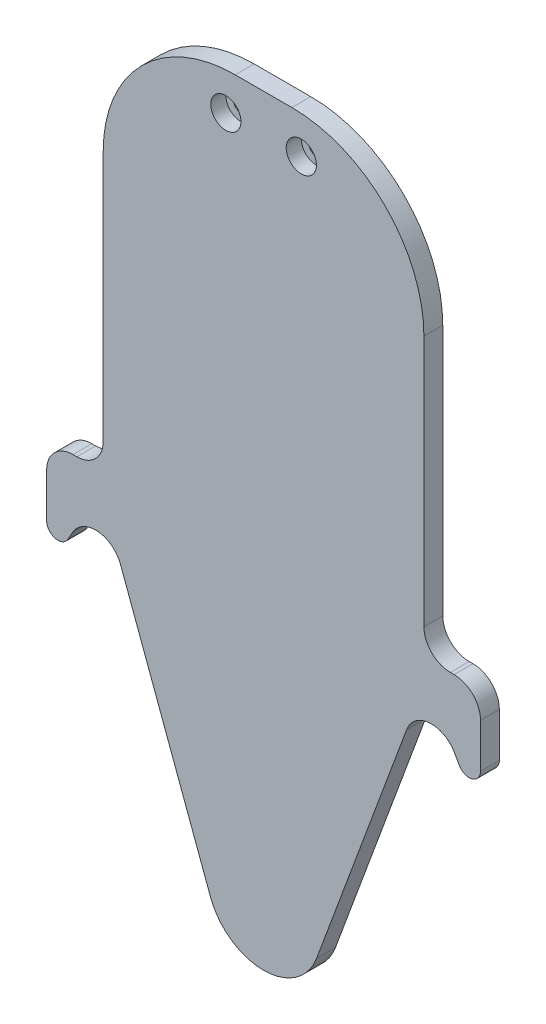
from build123d import *

# Parameters (mm, degrees)
DODANIE_WYCI_GNI_CIE1_DEPTH = 5
WYTNIJ_WYCI_GNI_CIE1_DEPTH  = 1
SZKIC3_R                    = 2
WYTNIJ_WYCI_GNI_CIE2_DEPTH  = 5
SZKIC4_R                    = 4
WYTNIJ_WYCI_GNI_CIE3_DEPTH  = 4
SZKIC5_R                    = 5
SZKIC5_R_2                  = 2
DODANIE_WYCI_GNI_CIE2_DEPTH = 5
ZAOKR_GLENIE1_R             = 2


with BuildPart() as part:
    # Szkic1 → Dodanie-wyciągnięcie1 (new body)
    with BuildSketch(Plane.XY):
        with BuildLine():
            Line((-37.935722713, 2.431103393), (-14.066308471, -62.019242173))
            ThreePointArc((-14.066308471, -62.019242173), (0, -71.809734903), (14.066308471, -62.019242173))
            Line((14.066308471, -62.019242173), (37.935722713, 2.431103393))
            ThreePointArc((37.935722713, 2.431103393), (43.929144479, 6.976684311), (50.581769351, 3.465845))
            Line((50.581769351, 3.465845), (51.893527421, 1.164008066))
            ThreePointArc((51.893527421, 1.164008066), (55.268304062, -0.250579595), (57.5, 2.649370209))
            Line((57.5, 2.649370209), (57.5, 14.325924396))
            ThreePointArc((57.5, 14.325924396), (55.449747468, 19.275671864), (50.5, 21.325924396))
            Line((50.5, 21.325924396), (49.5, 21.325924396))
            ThreePointArc((49.5, 21.325924396), (44.550252532, 23.376176928), (42.5, 28.325924396))
            Line((42.5, 28.325924396), (42.5, 95))
            ThreePointArc((42.5, 95), (32.248737342, 119.748737342), (7.5, 130))
            Line((7.5, 130), (-7.5, 130))
            ThreePointArc((-7.5, 130), (-32.248737342, 119.748737342), (-42.5, 95))
            Line((-42.5, 95), (-42.5, 28.325924396))
            ThreePointArc((-42.5, 28.325924396), (-44.550252532, 23.376176928), (-49.5, 21.325924396))
            Line((-49.5, 21.325924396), (-50.5, 21.325924396))
            ThreePointArc((-50.5, 21.325924396), (-55.449747468, 19.275671864), (-57.5, 14.325924396))
            Line((-57.5, 14.325924396), (-57.5, 2.649370209))
            ThreePointArc((-57.5, 2.649370209), (-55.268304062, -0.250579595), (-51.893527421, 1.164008066))
            Line((-51.893527421, 1.164008066), (-50.581769351, 3.465845))
            ThreePointArc((-50.581769351, 3.465845), (-43.929144479, 6.976684311), (-37.935722713, 2.431103393))
        make_face()
    extrude(amount=DODANIE_WYCI_GNI_CIE1_DEPTH)

    # Szkic2 → Wytnij-wyciągnięcie1 (cut)
    with BuildSketch(Plane(origin=(0, 0, 0), x_dir=(-1, 0, 0), z_dir=(0, 0, -1))):
        with BuildLine():
            Line((-27, 78), (27, 78))
            ThreePointArc((27, 78), (29.121320344, 77.121320344), (30, 75))
            Line((30, 75), (30, -9))
            ThreePointArc((30, -9), (29.121320344, -11.121320344), (27, -12))
            Line((27, -12), (-27, -12))
            ThreePointArc((-27, -12), (-29.121320344, -11.121320344), (-30, -9))
            Line((-30, -9), (-30, 75))
            ThreePointArc((-30, 75), (-29.121320344, 77.121320344), (-27, 78))
        make_face()
    extrude(amount=-WYTNIJ_WYCI_GNI_CIE1_DEPTH, mode=Mode.SUBTRACT)

    # Szkic3 → Wytnij-wyciągnięcie2 (cut)
    with BuildSketch(Plane(origin=(0, 0, 0), x_dir=(-1, 0, 0), z_dir=(0, 0, -1))):
        with Locations((-10, 120)):
            Circle(SZKIC3_R)
        with Locations((10, 120)):
            Circle(SZKIC3_R)
    extrude(amount=-WYTNIJ_WYCI_GNI_CIE2_DEPTH, mode=Mode.SUBTRACT)

    # Szkic4 → Wytnij-wyciągnięcie3 (cut)
    with BuildSketch(Plane.XY.offset(5)):
        with Locations((-10, 120)):
            Circle(SZKIC4_R)
        with Locations((10, 120)):
            Circle(SZKIC4_R)
    extrude(amount=-WYTNIJ_WYCI_GNI_CIE3_DEPTH, mode=Mode.SUBTRACT)

    # Szkic5 → Dodanie-wyciągnięcie2 (add)
    with BuildSketch(Plane(origin=(0, 0, 0), x_dir=(-1, 0, 0), z_dir=(0, 0, -1))):
        with Locations((-10, 120)):
            Circle(SZKIC5_R)
        with Locations((-10, 120)):
            Circle(SZKIC5_R_2, mode=Mode.SUBTRACT)
        with Locations((10, 120)):
            Circle(SZKIC5_R)
        with Locations((10, 120)):
            Circle(SZKIC5_R_2, mode=Mode.SUBTRACT)
    extrude(amount=DODANIE_WYCI_GNI_CIE2_DEPTH)

    # Zaokrąglenie1
    zaokr_glenie1_edges = [part.edges().sort_by_distance(p)[0] for p in [
        (15, 120, -5),
        (15, 120, 0),
        (-5, 120, -5),
        (-5, 120, 0),
    ]]
    fillet(zaokr_glenie1_edges, radius=ZAOKR_GLENIE1_R)


solid = part.part
